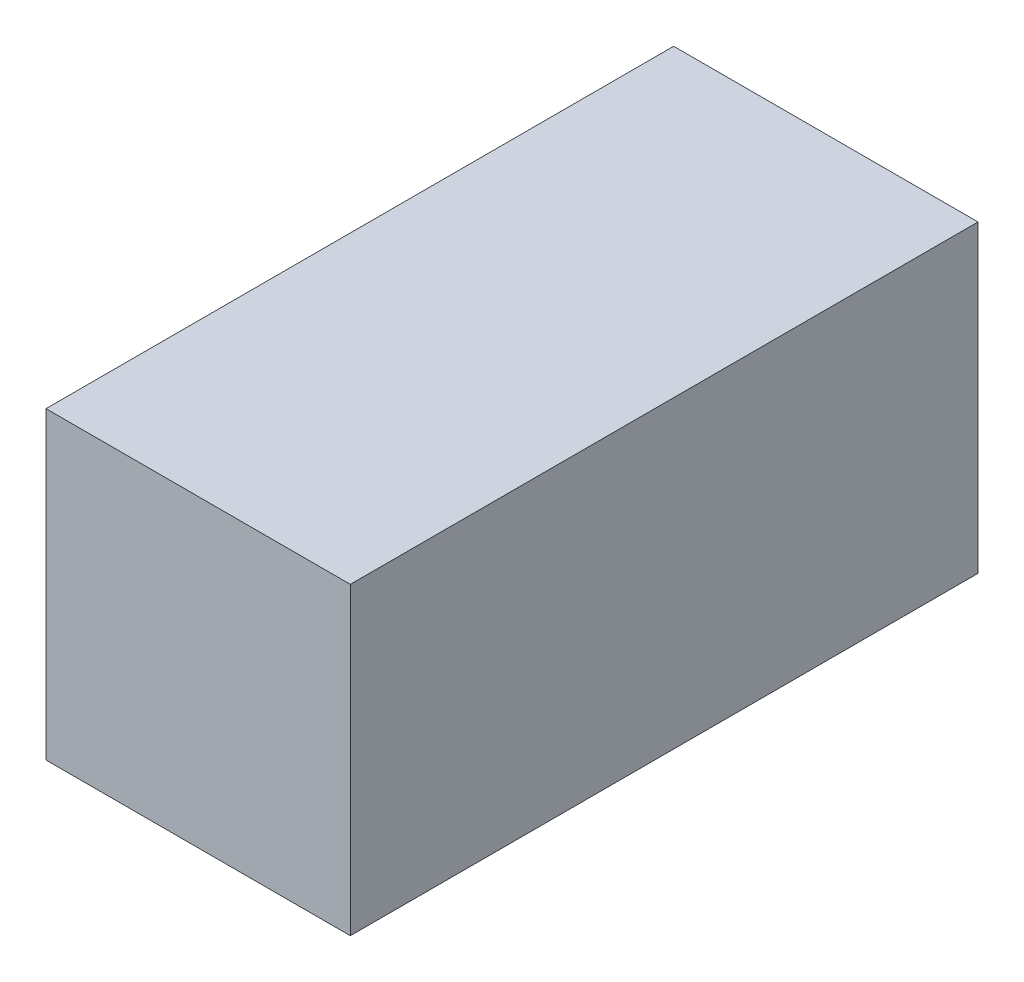
from build123d import *

# Parameters (mm, degrees)
ESQUISSE1_W        = 80
ESQUISSE1_H        = 80
BOSS_EXTRU_1_DEPTH = 165


with BuildPart() as part:
    # Esquisse1 → Boss.-Extru.1 (new body)
    with BuildSketch(Plane.XY):
        with Locations((9.050187266, -16.479400749)):
            Rectangle(ESQUISSE1_W, ESQUISSE1_H)
    extrude(amount=BOSS_EXTRU_1_DEPTH)


solid = part.part
